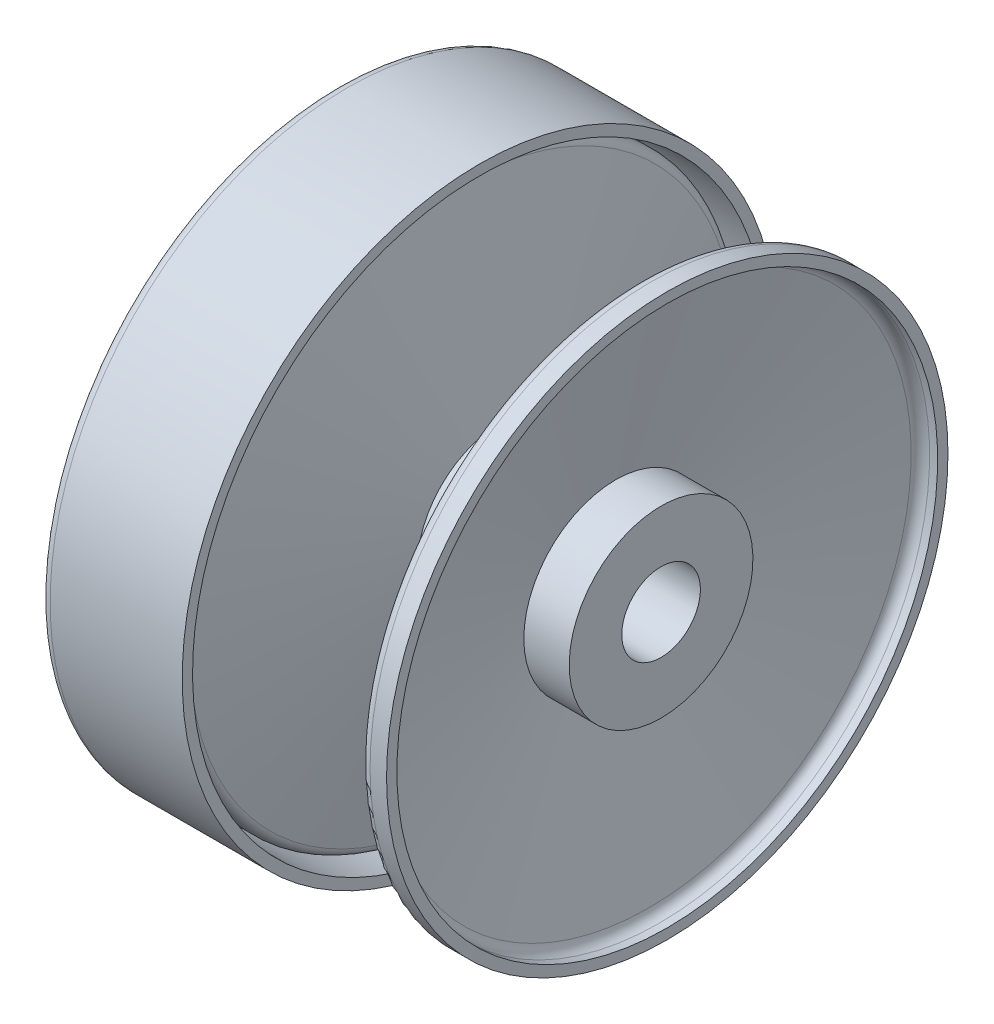
from build123d import *

# Parameters (mm, degrees)
FILLET_1_R          = 2.5
SKETCH_2_OUTSIDE_W  = 191.374
SKETCH_2_OUTSIDE_H  = 191.374
CUT_EXTRUDE_1_DEPTH = 9


with BuildPart() as part:
    # Эскиз1 → Повернуть1 (revolve)
    with BuildSketch(Plane.XY):
        Polygon((-36, 9.525), (48.5, 9.525), (48.5, 22.25), (37.5, 22.25), (46, 65.5), (50, 65.5), (50, 68), (43.943505966, 68), (34.509979954, 20), (9.433526012, 20), (0, 68), (-6.056494034, 68), (-6.056494034, 65.5), (-2.056494034, 65.5), (6.443505966, 22.25), (-15, 22.25), (-15, 69.5), (4.5, 69.5), (4.5, 72), (-30, 72), (-30, 52), (-41, 46.5), (-41, 25.75), (-50, 25.75), (-50, 12.75), (-41, 12.75), (-41, 4.25), (-36, 4.25), align=None)
    revolve(axis=Axis((-50, 0, 0), (1, 0, 0)))

    # Скругление1
    fillet_1_edges = [part.edges().sort_by_distance(p)[0] for p in [
        (0, -68, 0),
        (43.943505966, -68, 0),
        (46, -65.5, 0),
        (-41, -46.5, 0),
        (-30, -52, 0),
        (-30, -72, 0),
    ]]
    fillet(fillet_1_edges, radius=FILLET_1_R)

    # Эскиз2 outside → Вырез-Вытянуть1 (cut)
    with BuildSketch(Plane.ZY.offset(50)):
        Rectangle(SKETCH_2_OUTSIDE_W, SKETCH_2_OUTSIDE_H)
        Polygon((0, 25.75), (-22.300154147, 12.875), (-22.300154147, -12.875), (0, -25.75), (22.300154147, -12.875), (22.300154147, 12.875), align=None, mode=Mode.SUBTRACT)
    extrude(amount=-CUT_EXTRUDE_1_DEPTH, mode=Mode.SUBTRACT)


solid = part.part
